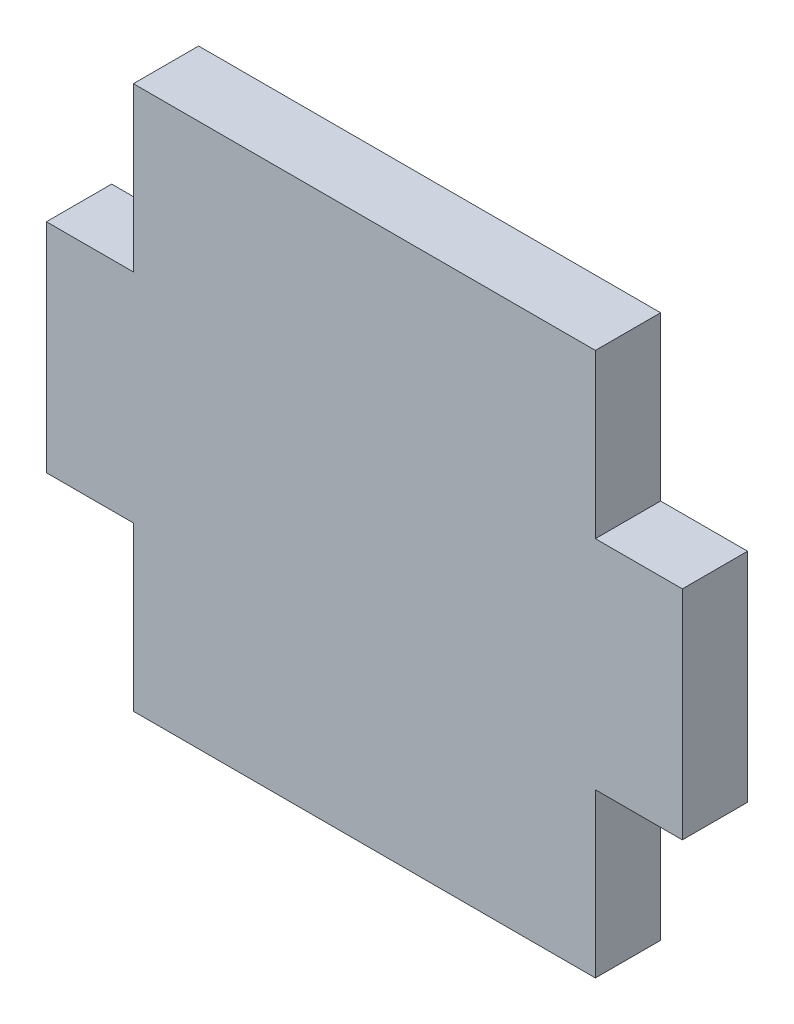
from build123d import *

# Parameters (mm, degrees)
SALIENTE_EXTRUIR1_DEPTH = 3


with BuildPart() as part:
    # Croquis1 → Saliente-Extruir1 (new body)
    with BuildSketch(Plane.XY):
        Polygon((-10.625, 12.5), (10.625, 12.5), (10.625, 5), (14.625, 5), (14.625, -5), (10.625, -5), (10.625, -12.5), (-10.625, -12.5), (-10.625, -5), (-14.625, -5), (-14.625, 5), (-10.625, 5), align=None)
    extrude(amount=SALIENTE_EXTRUIR1_DEPTH)


solid = part.part
